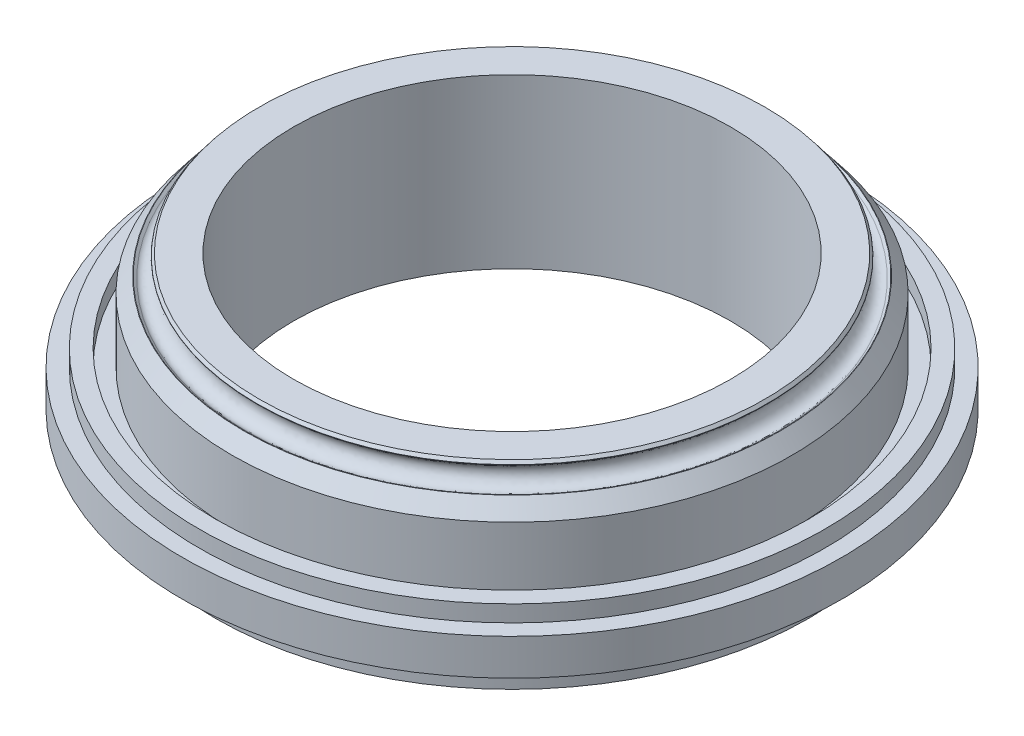
from build123d import *

# Parameters (mm, degrees)
FILLET2_R          = 0.1
SKETCH2_R          = 1.55
CUT_EXTRUDE1_DEPTH = 10


with BuildPart() as part:
    # Sketch1 → Revolve1 (revolve)
    with BuildSketch(Plane.XY):
        with BuildLine():
            Line((76.75, 40.74810371), (66.326451616, 40.74810371))
            Line((66.326451616, 40.74810371), (66.326451616, -10.262378674))
            Line((66.326451616, -10.262378674), (75.3, -10.262378674))
            add(Edge.make_bspline(
                [(81.8, -10.262378674), (81.8, -8.097378674), (78.55, -8.097378674), (75.3, -8.097378674), (75.3, -10.262378674)],
                knots=[0, 0, 0, 1.570796327, 1.570796327, 3.141592654, 3.141592654, 3.141592654], degree=2, weights=[1, 0.707106781, 1, 0.707106781, 1]))
            Line((81.8, -10.262378674), (90, -10.262378674))
            Line((90, -10.262378674), (90, -0.262378674))
            Line((90, -0.262378674), (100, -0.262378674))
            Line((100, -0.262378674), (100, 10.737621326))
            Line((100, 10.737621326), (95, 10.737621326))
            Line((95, 10.737621326), (95, 15.737621326))
            Line((95, 15.737621326), (89.9, 15.737621326))
            Line((89.9, 15.737621326), (89.9, 10.737621326))
            Line((89.9, 10.737621326), (84.99, 10.737621326))
            Line((84.99, 10.737621326), (84.99, 30.117499507))
            Line((84.99, 30.117499507), (81.364088934, 34.79536667))
            Line((81.364088934, 34.79536667), (80.521555676, 34.142301811))
            add(Edge.make_bspline(
                [(76.631347555, 39.161144384), (74.517110723, 37.522355923), (76.462214784, 35.012934637), (78.407318844, 32.50351335), (80.521555676, 34.142301811)],
                knots=[0, 0, 0, 1.570796327, 1.570796327, 3.141592654, 3.141592654, 3.141592654], degree=2, weights=[1, 0.707106781, 1, 0.707106781, 1]))
            Line((76.631347555, 39.161144384), (77.473880812, 39.814209243))
            Line((77.473880812, 39.814209243), (76.75, 40.74810371))
        make_face()
    revolve(axis=Axis((0, 0, 0), (0, 1, 0)))

    # Fillet2
    fillet2_edges = [part.edges().sort_by_distance(p)[0] for p in [
        (-77.473880812, 39.814209243, 0),
        (-81.364088934, 34.79536667, 0),
    ]]
    fillet(fillet2_edges, radius=FILLET2_R)

    # Sketch2 → Cut-Extrude1 (cut)
    with BuildSketch(Plane.XZ.offset(10.262378674)):
        with Locations((0, 85)):
            Circle(SKETCH2_R)
        with Locations((42.5, 73.612159322)):
            Circle(SKETCH2_R)
        with Locations((73.612159322, 42.5)):
            Circle(SKETCH2_R)
        with Locations((85, 0)):
            Circle(SKETCH2_R)
        with Locations((73.612159322, -42.5)):
            Circle(SKETCH2_R)
        with Locations((42.5, -73.612159322)):
            Circle(SKETCH2_R)
        with Locations((0, -85)):
            Circle(SKETCH2_R)
        with Locations((-42.5, -73.612159322)):
            Circle(SKETCH2_R)
        with Locations((-73.612159322, -42.5)):
            Circle(SKETCH2_R)
        with Locations((-85, 0)):
            Circle(SKETCH2_R)
        with Locations((-73.612159322, 42.5)):
            Circle(SKETCH2_R)
        with Locations((-42.5, 73.612159322)):
            Circle(SKETCH2_R)
    extrude(amount=-CUT_EXTRUDE1_DEPTH, mode=Mode.SUBTRACT)


solid = part.part
